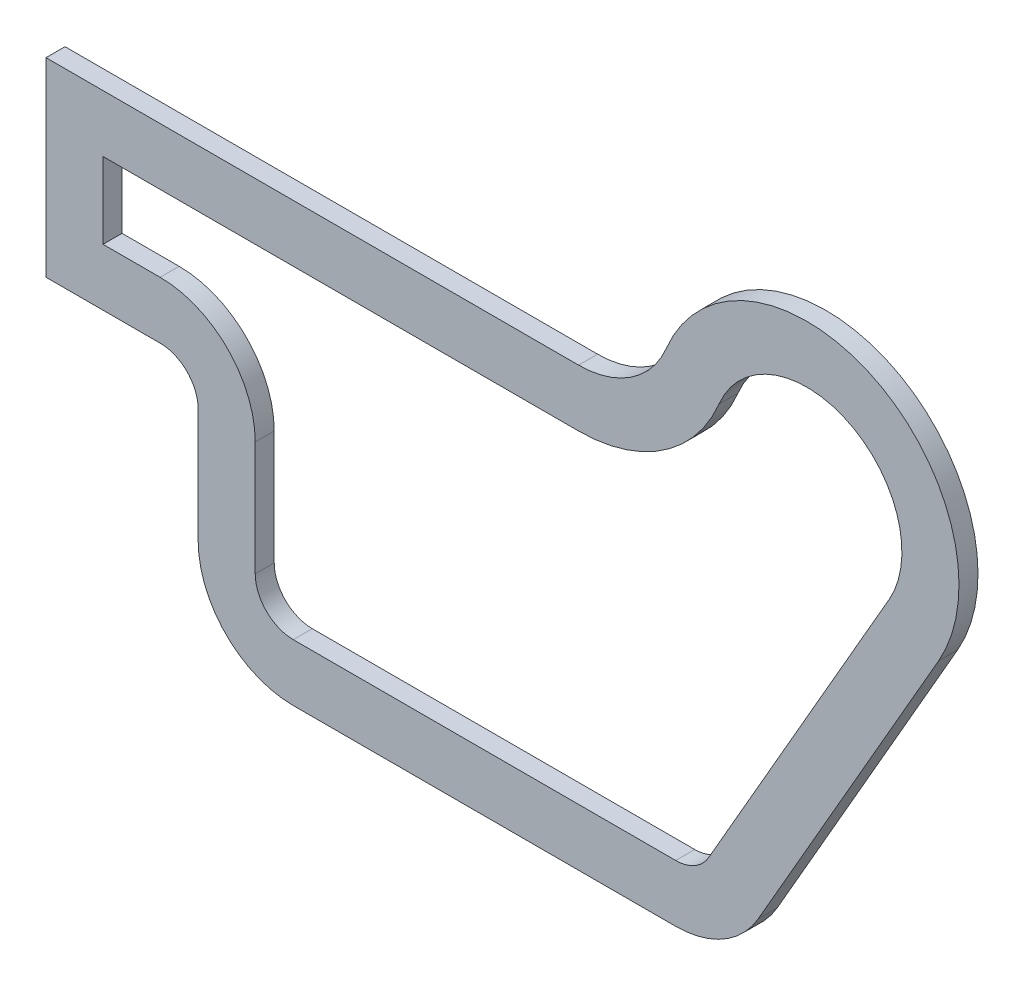
from build123d import *

# Parameters (mm, degrees)
BOSS_EXTRUDE1_DEPTH = 5
SHELL1_T            = -15


with BuildPart() as part:
    # Sketch1 → Boss-Extrude1 (new body)
    with BuildSketch(Plane.XY):
        with BuildLine():
            Line((140, 115), (0, 115))
            Line((0, 115), (0, 65))
            Line((0, 65), (30, 65))
            ThreePointArc((30, 65), (37.071067812, 62.071067812), (40, 55))
            Line((40, 55), (40, 25))
            ThreePointArc((40, 25), (47.32233047, 7.32233047), (65, 0))
            Line((65, 0), (165.538941775, 0))
            ThreePointArc((165.538941775, 0), (178.05666204, 3.359605379), (187.210014279, 12.535465651))
            Line((187.210014279, 12.535465651), (234.673716006, 95.056745042))
            ThreePointArc((234.673716006, 95.056745042), (217.699703722, 150.870886358), (163.076923077, 130.384615385))
            ThreePointArc((163.076923077, 130.384615385), (153.867504906, 119.198742642), (140, 115))
        make_face()
    extrude(amount=BOSS_EXTRUDE1_DEPTH)

    # Shell1
    shell1_openings = [part.faces().sort_by_distance(p)[0] for p in [
        (98.657145907, 64.238067092, 5),
        (98.657145907, 64.238067092, 0),
    ]]
    offset(amount=SHELL1_T, openings=shell1_openings, kind=Kind.INTERSECTION)


solid = part.part
